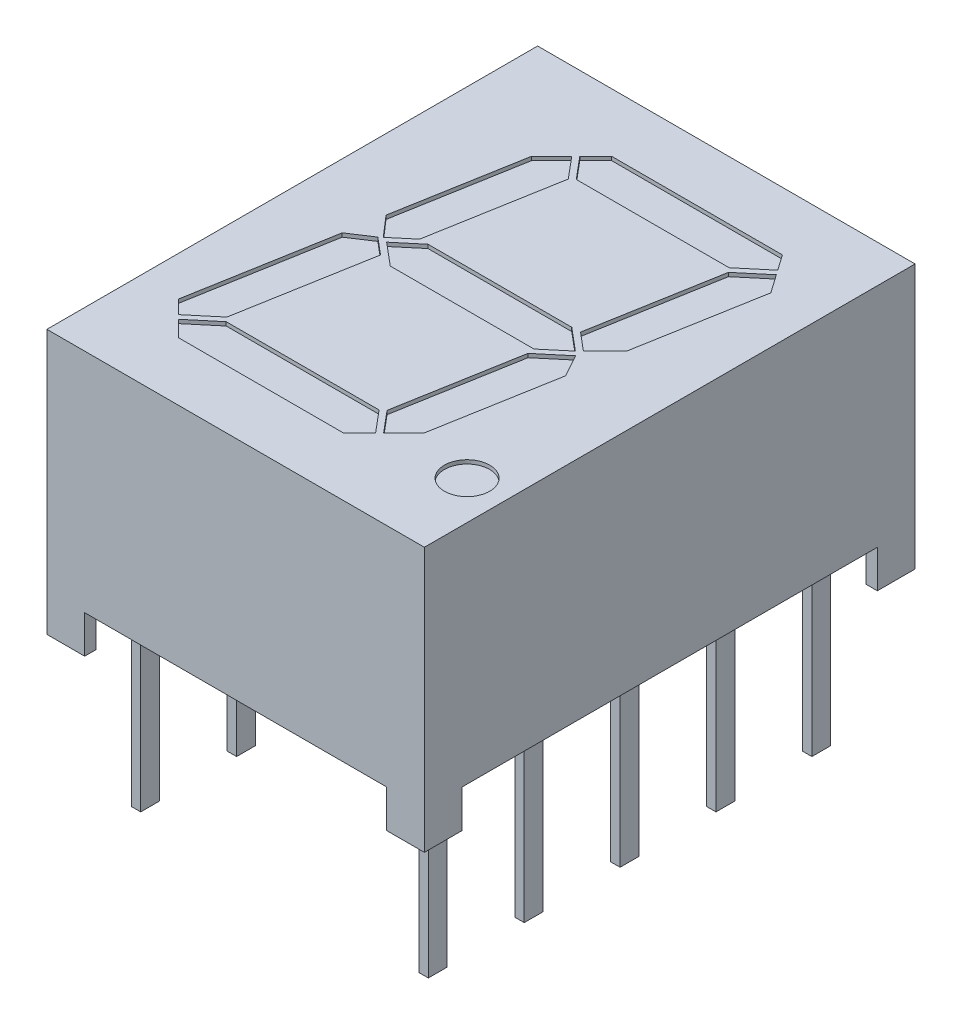
from build123d import *

# Parameters (mm, degrees)
SKETCH1_W          = 10
SKETCH1_H          = 13
EXTRUDE2_DEPTH     = 7
SKETCH2_W          = 4
SKETCH2_H          = 1
CUT_EXTRUDE2_DEPTH = 16.588457268
SKETCH3_W          = 11
SKETCH3_H          = 1
CUT_EXTRUDE3_DEPTH = 14.829316686
SKETCH6_R          = 0.6
CUT_EXTRUDE4_DEPTH = 0.1
SKETCH7_W          = 0.7
SKETCH7_H          = 0.7
CUT_EXTRUDE6_DEPTH = 1
SKETCH7_3_W        = 0.25
SKETCH7_3_H        = 0.5
EXTRUDE3_DEPTH     = 1
SKETCH7_4_W        = 0.7
SKETCH7_4_H        = 0.7
SKETCH7_4_W_2      = 0.25
SKETCH7_4_H_2      = 0.5
EXTRUDE4_DEPTH     = 4
SKETCH8_W          = 0.025316456
SKETCH8_H          = 0.026582279
SKETCH8_W_2        = 0.025316455
CUT_EXTRUDE7_DEPTH = 0.01


with BuildPart() as part:
    # Sketch1 → Extrude2 (new body)
    with BuildSketch(Plane(origin=(0, 0, 0), x_dir=(1, 0, 0), z_dir=(0, 1, 0))):
        Rectangle(SKETCH1_W, SKETCH1_H)
    extrude(amount=-EXTRUDE2_DEPTH)

    # Sketch2 → Cut-Extrude2 (cut, through all)
    with BuildSketch(Plane.XY.offset(6.5)):
        with Locations((-2, -6.5)):
            Rectangle(SKETCH2_W, SKETCH2_H)
        with Locations((2, -6.5)):
            Rectangle(SKETCH2_W, SKETCH2_H)
    extrude(amount=-CUT_EXTRUDE2_DEPTH, mode=Mode.SUBTRACT)

    # Sketch3 → Cut-Extrude3 (cut, through all)
    with BuildSketch(Plane(origin=(5, 0, 0), x_dir=(0, 0, -1), z_dir=(1, 0, 0))):
        with Locations((0, -6.5)):
            Rectangle(SKETCH3_W, SKETCH3_H)
    extrude(amount=-CUT_EXTRUDE3_DEPTH, mode=Mode.SUBTRACT)

    # Sketch6 → Cut-Extrude4 (cut)
    with BuildSketch(Plane(origin=(0, 0, 0), x_dir=(-1, 0, 0), z_dir=(0, 1, 0))):
        Polygon((2.01780111, -4.421729157), (2.550190438, -3.889339828), (3.128122122, -0.611726379), (2.654628224, -0.066062608), (2.131512729, -0.505008627), (1.541068921, -3.853581859), align=None)
        Polygon((2.733358574, 0), (3.302068733, 0.374773874), (3.952952037, 4.066116524), (3.596689581, 4.422378979), (2.896789804, 3.835093334), (2.286652218, 0.374831138), align=None)
        Polygon((1.489530267, -4.95), (1.911329938, -4.528200329), (1.426162255, -3.95), (-2.624044681, -3.95), (-3.323944459, -4.537285646), (-3.034958757, -4.95), align=None)
        Polygon((1.904123204, -0.5), (2.5, 0), (1.904123204, 0.5), (-1.904123204, 0.5), (-2.5, 0), (-1.904123204, -0.5), align=None)
        Polygon((2.800371662, 3.95), (3.490218409, 4.528850151), (3.069068561, 4.95), (-1.313203286, 4.95), (-1.735002957, 4.528200329), (-1.249835274, 3.95), align=None)
        Polygon((-3.41030957, -4.413943485), (-2.720462823, -3.835093334), (-2.133051387, -0.503717539), (-2.598749395, -0.112950513), (-3.18025084, -0.683910271), (-3.751929303, -3.926059945), align=None)
        Polygon((-1.924566889, 0.678656804), (-1.364741941, 3.853581859), (-1.841474129, 4.421729157), (-2.373863458, 3.889339828), (-2.936942063, 0.695962372), (-2.611721221, 0.102065858), align=None)
        with Locations(Location((-3.980686632, 4.35, 0), (0, 0, 90))):
            Circle(SKETCH6_R)
    extrude(amount=-CUT_EXTRUDE4_DEPTH, mode=Mode.SUBTRACT)

    # Sketch7 → Cut-Extrude6 (cut)
    with BuildSketch(Plane.XZ.offset(7)):
        with Locations((-4.35, 5.85)):
            Rectangle(SKETCH7_W, SKETCH7_H)
        with Locations((-4.35, -5.85)):
            Rectangle(SKETCH7_W, SKETCH7_H)
        with Locations((4.35, -5.85)):
            Rectangle(SKETCH7_W, SKETCH7_H)
        with Locations((4.35, 5.85)):
            Rectangle(SKETCH7_W, SKETCH7_H)
    extrude(amount=-CUT_EXTRUDE6_DEPTH, mode=Mode.SUBTRACT)

    # Sketch7_3 → Extrude3 (add)
    with BuildSketch(Plane.XZ.offset(7)):
        with Locations((-3.81, 5.08)):
            Rectangle(SKETCH7_3_W, SKETCH7_3_H)
        with Locations((3.81, -5.08)):
            Rectangle(SKETCH7_3_W, SKETCH7_3_H)
        with Locations((-3.81, 2.54)):
            Rectangle(SKETCH7_3_W, SKETCH7_3_H)
        with Locations((-3.81, 0)):
            Rectangle(SKETCH7_3_W, SKETCH7_3_H)
        with Locations((-3.81, -2.54)):
            Rectangle(SKETCH7_3_W, SKETCH7_3_H)
        with Locations((-3.81, -5.08)):
            Rectangle(SKETCH7_3_W, SKETCH7_3_H)
        with Locations((3.81, -2.54)):
            Rectangle(SKETCH7_3_W, SKETCH7_3_H)
        with Locations((3.81, 0)):
            Rectangle(SKETCH7_3_W, SKETCH7_3_H)
        with Locations((3.81, 2.54)):
            Rectangle(SKETCH7_3_W, SKETCH7_3_H)
        with Locations((3.81, 5.08)):
            Rectangle(SKETCH7_3_W, SKETCH7_3_H)
    extrude(amount=-EXTRUDE3_DEPTH)


with BuildPart() as extrude4_tool:
    # Sketch7_4 → Extrude4 (new body)
    with BuildSketch(Plane.XZ.offset(7)):
        with Locations((-4.35, 5.85)):
            Rectangle(SKETCH7_4_W, SKETCH7_4_H)
        with Locations((-4.35, -5.85)):
            Rectangle(SKETCH7_4_W, SKETCH7_4_H)
        with Locations((4.35, -5.85)):
            Rectangle(SKETCH7_4_W, SKETCH7_4_H)
        with Locations((4.35, 5.85)):
            Rectangle(SKETCH7_4_W, SKETCH7_4_H)
        with Locations((-3.81, 5.08)):
            Rectangle(SKETCH7_4_W_2, SKETCH7_4_H_2)
        with Locations((3.81, -5.08)):
            Rectangle(SKETCH7_4_W_2, SKETCH7_4_H_2)
        with Locations((-3.81, 2.54)):
            Rectangle(SKETCH7_4_W_2, SKETCH7_4_H_2)
        with Locations((-3.81, 0)):
            Rectangle(SKETCH7_4_W_2, SKETCH7_4_H_2)
        with Locations((-3.81, -2.54)):
            Rectangle(SKETCH7_4_W_2, SKETCH7_4_H_2)
        with Locations((-3.81, -5.08)):
            Rectangle(SKETCH7_4_W_2, SKETCH7_4_H_2)
        with Locations((3.81, -2.54)):
            Rectangle(SKETCH7_4_W_2, SKETCH7_4_H_2)
        with Locations((3.81, 0)):
            Rectangle(SKETCH7_4_W_2, SKETCH7_4_H_2)
        with Locations((3.81, 2.54)):
            Rectangle(SKETCH7_4_W_2, SKETCH7_4_H_2)
        with Locations((3.81, 5.08)):
            Rectangle(SKETCH7_4_W_2, SKETCH7_4_H_2)
    extrude(amount=EXTRUDE4_DEPTH)


with BuildPart() as part_1:
    add(part.part)


with BuildPart() as part_2:
    # Extrude4: joined with extrude4_tool
    add(part_1.part.fuse(extrude4_tool.part, tol=0.00001))


with BuildPart() as extrude4_kept_piece:
    # of the separate pieces the step leaves, the one the design keeps (extrude4_pieces_kept)
    add(part_2.part.solids().sort_by_distance((-5, 0, -6.5))[0])

    # Sketch8 → Cut-Extrude7 (cut)
    with BuildSketch(Plane.XZ.offset(6)):
        Polygon((0.542632818, 5.007606152), (0.566090097, 5.082289696), (0.590832977, 5.082289696), (0.607249116, 5.031953462), (0.622775223, 5.082289696), (0.648507027, 5.082289696), (0.671746742, 5.007606152), (0.646568736, 5.007606152), (0.633574274, 5.059089538), (0.617158135, 5.007606152), (0.595658926, 5.007606152), (0.579341679, 5.059089538), (0.566525223, 5.007606152), align=None)
        Polygon((0.408455622, 5.007535676), (0.4319129, 5.08221922), (0.45665578, 5.08221922), (0.473071919, 5.031882986), (0.488598027, 5.08221922), (0.514329831, 5.08221922), (0.537569546, 5.007535676), (0.512391539, 5.007535676), (0.499397077, 5.059019062), (0.482980938, 5.007535676), (0.461481729, 5.007535676), (0.445164483, 5.059019062), (0.432348027, 5.007535676), align=None)
        Polygon((0.274278425, 5.0074652), (0.297735704, 5.082148744), (0.322478583, 5.082148744), (0.338894723, 5.03181251), (0.35442083, 5.082148744), (0.380152634, 5.082148744), (0.403392349, 5.0074652), (0.378214343, 5.0074652), (0.365219881, 5.058948586), (0.348803742, 5.0074652), (0.327304533, 5.0074652), (0.310987286, 5.058948586), (0.29817083, 5.0074652), align=None)
        with Locations((0.246430342, 5.068787129)):
            Rectangle(SKETCH8_W, SKETCH8_H)
        with BuildLine():
            add(Edge.make_bspline(
                [(0.129974653, 5.050881452), (0.130011181, 5.052103566), (0.13008291, 5.05450339), (0.130692072, 5.058011356), (0.131687596, 5.061334639), (0.133051935, 5.064497355), (0.134865923, 5.067452721), (0.137020936, 5.070271288), (0.139632851, 5.07285525), (0.142569887, 5.075294011), (0.145867814, 5.077476406), (0.149470436, 5.079376544), (0.153340756, 5.081001263), (0.157494777, 5.082332953), (0.161940354, 5.08332372), (0.166658131, 5.084047037), (0.171651479, 5.084520545), (0.175075067, 5.084562486), (0.176829874, 5.084583984)],
                knots=[0, 0, 0, 0, 0.907421153, 1.781872267, 2.635683434, 3.480115191, 4.332689235, 5.205575272, 6.109500117, 7.055808355, 8.037942167, 9.041423561, 10.07750834, 11.152467461, 12.277657752, 13.45734338, 14.696726425, 16, 16, 16, 16], degree=3))
            add(Edge.make_bspline(
                [(0.176829874, 5.084583984), (0.178847859, 5.084556719), (0.182756045, 5.084503915), (0.188423613, 5.084118542), (0.19368708, 5.083430592), (0.198584827, 5.082474012), (0.203189127, 5.081270727), (0.207622472, 5.079980083), (0.211903764, 5.078515502), (0.214676856, 5.077415366), (0.216050602, 5.076870376)],
                knots=[0, 0, 0, 0, 1.203182053, 2.33017619, 3.384818652, 4.366208123, 5.30340534, 6.221361684, 7.118890722, 8, 8, 8, 8], degree=3))
            Line((0.216050602, 5.076870376), (0.216050602, 5.052938414))
            Line((0.216050602, 5.052938414), (0.213202501, 5.052938414))
            add(Edge.make_bspline(
                [(0.213202501, 5.052938414), (0.211836938, 5.054019377), (0.209113828, 5.056174956), (0.20468687, 5.05894331), (0.200027858, 5.06131632), (0.195189464, 5.063298943), (0.190288096, 5.064874557), (0.185419028, 5.066001463), (0.180650046, 5.066740827), (0.177491724, 5.066822388), (0.175939843, 5.066862465)],
                knots=[0, 0, 0, 0, 1.030738938, 2.055426519, 3.085610749, 4.123842265, 5.148648843, 6.130724483, 7.081507926, 8, 8, 8, 8], degree=3))
            add(Edge.make_bspline(
                [(0.175939843, 5.066862465), (0.175511097, 5.066861164), (0.174593184, 5.066858379), (0.173124036, 5.066737064), (0.171467693, 5.06660922), (0.169686954, 5.066413106), (0.16789975, 5.066181961), (0.166239502, 5.065835494), (0.16473874, 5.065466343), (0.163832071, 5.065099077), (0.163400286, 5.064924173)],
                knots=[0, 0, 0, 0, 0.806537132, 1.726733348, 2.77251655, 3.932999672, 5.098049949, 6.161349231, 7.124375527, 8, 8, 8, 8], degree=3))
            add(Edge.make_bspline(
                [(0.163400286, 5.064924173), (0.1629208, 5.064695938), (0.161978507, 5.064247406), (0.160675976, 5.063433496), (0.159505491, 5.062538751), (0.158444789, 5.061577018), (0.157582394, 5.06041403), (0.156961233, 5.059014759), (0.156616662, 5.057365466), (0.15657759, 5.056190304), (0.156556931, 5.055568952)],
                knots=[0, 0, 0, 0, 1.02474257, 2.013837243, 2.958431669, 3.867978675, 4.769292696, 5.732237074, 6.800947934, 8, 8, 8, 8], degree=3))
            add(Edge.make_bspline(
                [(0.156556931, 5.055568952), (0.156588393, 5.055023086), (0.156650255, 5.053949752), (0.157231761, 5.052421322), (0.158115808, 5.051001186), (0.159395223, 5.04973585), (0.161008902, 5.048609738), (0.162939889, 5.047598975), (0.165213739, 5.046763217), (0.166850952, 5.046325345), (0.167711995, 5.04609506)],
                knots=[0, 0, 0, 0, 0.825427492, 1.623033598, 2.45033906, 3.348940377, 4.33183287, 5.428402891, 6.647546779, 8, 8, 8, 8], degree=3))
            add(Edge.make_bspline(
                [(0.167711995, 5.04609506), (0.169681235, 5.045649855), (0.173716447, 5.044737577), (0.17985626, 5.043550123), (0.185994963, 5.042324252), (0.18995122, 5.041109937), (0.191881298, 5.040517528)],
                knots=[0, 0, 0, 0, 0.976118991, 2.000185432, 3.024380873, 4, 4, 4, 4], degree=3))
            add(Edge.make_bspline(
                [(0.191881298, 5.040517528), (0.192919451, 5.040163805), (0.194940313, 5.039475251), (0.197839505, 5.038322602), (0.200482753, 5.037017468), (0.202940292, 5.03569543), (0.205132956, 5.034215372), (0.20712759, 5.032682613), (0.20888025, 5.031029808), (0.210406688, 5.029280316), (0.211749554, 5.027443954), (0.212902964, 5.025496813), (0.213863986, 5.023430363), (0.214687378, 5.021274966), (0.215298605, 5.019000431), (0.215721041, 5.016624014), (0.216019104, 5.014140527), (0.21603996, 5.012446192), (0.216050602, 5.01158161)],
                knots=[0, 0, 0, 0, 1.287376879, 2.505999703, 3.65855109, 4.746193839, 5.778582289, 6.760029101, 7.696159662, 8.601061861, 9.48181646, 10.363080883, 11.252765705, 12.153987336, 13.068239035, 14.012364187, 14.985753787, 16, 16, 16, 16], degree=3))
            add(Edge.make_bspline(
                [(0.216050602, 5.01158161), (0.216013302, 5.010425464), (0.215939895, 5.008150189), (0.215338445, 5.004821166), (0.214311935, 5.001672348), (0.212925575, 4.998669192), (0.211098082, 4.995854928), (0.208905959, 4.993177442), (0.206295649, 4.990684946), (0.203310322, 4.988386309), (0.200023475, 4.986307504), (0.19648947, 4.984470796), (0.192710618, 4.982964349), (0.188730733, 4.981683118), (0.184511341, 4.980730722), (0.18007437, 4.980011145), (0.175400508, 4.979598144), (0.172209097, 4.979546869), (0.170579874, 4.979520692)],
                knots=[0, 0, 0, 0, 0.894901293, 1.761149761, 2.608783409, 3.453876344, 4.314933854, 5.200038827, 6.12799933, 7.103249695, 8.113098521, 9.136064399, 10.182719798, 11.259667356, 12.370545059, 13.528828137, 14.738461593, 16, 16, 16, 16], degree=3))
            add(Edge.make_bspline(
                [(0.170579874, 4.979520692), (0.168911223, 4.979543085), (0.165576749, 4.979587833), (0.160594776, 4.979962802), (0.155637361, 4.980529304), (0.150765797, 4.981328758), (0.14608329, 4.982346414), (0.141666676, 4.983432372), (0.137587706, 4.984672762), (0.135013981, 4.985626807), (0.133772121, 4.986087148)],
                knots=[0, 0, 0, 0, 1.065379838, 2.128953261, 3.188461447, 4.250817766, 5.279613205, 6.247547721, 7.154416075, 8, 8, 8, 8], degree=3))
            Line((0.133772121, 4.986087148), (0.133772121, 5.008634616))
            Line((0.133772121, 5.008634616), (0.136600444, 5.008634616))
            add(Edge.make_bspline(
                [(0.136600444, 5.008634616), (0.137673404, 5.007834413), (0.139867634, 5.006197975), (0.143526387, 5.004111998), (0.147490447, 5.002162484), (0.151755349, 5.000440691), (0.156227889, 4.99902009), (0.160805435, 4.997991046), (0.1654325, 4.997351923), (0.168534091, 4.99727879), (0.170085412, 4.997242211)],
                knots=[0, 0, 0, 0, 0.89224925, 1.824673196, 2.804309561, 3.838364047, 4.890042674, 5.931526337, 6.965412421, 8, 8, 8, 8], degree=3))
            add(Edge.make_bspline(
                [(0.170085412, 4.997242211), (0.171180712, 4.997266421), (0.173370458, 4.997314822), (0.176644865, 4.997664076), (0.179879657, 4.998335817), (0.181922555, 4.999150154), (0.182941425, 4.999556294)],
                knots=[0, 0, 0, 0, 0.998993879, 1.997209027, 3.00113285, 4, 4, 4, 4], degree=3))
            add(Edge.make_bspline(
                [(0.182941425, 4.999556294), (0.183374904, 4.999757776), (0.184241574, 5.000160608), (0.185448577, 5.000932933), (0.186551881, 5.001862651), (0.187552886, 5.002915045), (0.188400942, 5.00408438), (0.189038602, 5.005354139), (0.189399422, 5.006716118), (0.189445258, 5.007650286), (0.189468324, 5.008120376)],
                knots=[0, 0, 0, 0, 1.005454979, 2.010239304, 3.005296729, 4.036100111, 5.060531193, 6.034954812, 7.011155677, 8, 8, 8, 8], degree=3))
            add(Edge.make_bspline(
                [(0.189468324, 5.008120376), (0.189433529, 5.008758307), (0.189367041, 5.009977335), (0.188767043, 5.011691031), (0.187769374, 5.013154143), (0.186616275, 5.014147136), (0.185499296, 5.014845896), (0.184458779, 5.015351136), (0.183259328, 5.015864559), (0.181881879, 5.016353756), (0.180346744, 5.016847802), (0.178637822, 5.017322472), (0.176755214, 5.017772031), (0.175439324, 5.018058183), (0.174753134, 5.018207401)],
                knots=[0, 0, 0, 0, 1.174343879, 2.244064321, 3.303704314, 4.407076671, 5.02483983, 5.732197225, 6.53898402, 7.431906431, 8.428480183, 9.514816237, 10.704066255, 12, 12, 12, 12], degree=3))
            add(Edge.make_bspline(
                [(0.174753134, 5.018207401), (0.172920509, 5.018584121), (0.169319806, 5.019324293), (0.163914731, 5.02041859), (0.158421677, 5.021731107), (0.154751127, 5.02286032), (0.152838577, 5.023448699)],
                knots=[0, 0, 0, 0, 0.995788186, 1.956503735, 2.935230479, 4, 4, 4, 4], degree=3))
            add(Edge.make_bspline(
                [(0.152838577, 5.023448699), (0.15189202, 5.02376794), (0.150040403, 5.024392428), (0.147399805, 5.025478746), (0.144952632, 5.026652603), (0.142685998, 5.027894573), (0.140610632, 5.029237006), (0.138724342, 5.030662339), (0.137026385, 5.032167122), (0.135537637, 5.033782842), (0.134208879, 5.03549319), (0.133096535, 5.037343803), (0.13210095, 5.039287332), (0.131347795, 5.041380775), (0.130723286, 5.043579303), (0.130301543, 5.045911237), (0.13000718, 5.048355455), (0.129985616, 5.050030054), (0.129974653, 5.050881452)],
                knots=[0, 0, 0, 0, 1.237326419, 2.420410185, 3.534642089, 4.598489486, 5.620241961, 6.59385002, 7.525152549, 8.426792174, 9.312230456, 10.203151844, 11.098070343, 12.012931196, 12.954244379, 13.926618287, 14.945853925, 16, 16, 16, 16], degree=3))
        make_face()
        with BuildLine():
            Line((0.037569603, 5.082001143), (0.061620236, 5.082001143))
            Line((0.061620236, 5.082001143), (0.061620236, 5.074168865))
            add(Edge.make_bspline(
                [(0.061620236, 5.074168865), (0.06271343, 5.074977659), (0.064821091, 5.076537004), (0.067995651, 5.078614066), (0.07101395, 5.080398488), (0.073944303, 5.081921605), (0.076950579, 5.083133776), (0.080188714, 5.083952157), (0.08369031, 5.084454881), (0.08611738, 5.084506242), (0.087371818, 5.084532789)],
                knots=[0, 0, 0, 0, 1.150945962, 2.219006967, 3.209666795, 4.118194914, 5.012574058, 5.946577101, 6.93868214, 8, 8, 8, 8], degree=3))
            add(Edge.make_bspline(
                [(0.087371818, 5.084532789), (0.088388093, 5.084509841), (0.090367074, 5.084465155), (0.093245374, 5.084123434), (0.09594734, 5.083575025), (0.098476177, 5.082806619), (0.100825877, 5.081803588), (0.102969557, 5.080531953), (0.104972133, 5.079099239), (0.106754081, 5.077392874), (0.108369627, 5.075494955), (0.109752198, 5.073362546), (0.110929903, 5.071029606), (0.111871002, 5.068477756), (0.112626091, 5.065719452), (0.113150023, 5.062740205), (0.113470616, 5.059553077), (0.113502555, 5.057357947), (0.11351897, 5.056229782)],
                knots=[0, 0, 0, 0, 1.108959949, 2.159465255, 3.158589008, 4.114545495, 5.039534357, 5.93921201, 6.830099133, 7.720870013, 8.624681761, 9.544731627, 10.487599671, 11.471264588, 12.508152322, 13.604835107, 14.769030043, 16, 16, 16, 16], degree=3))
            Line((0.11351897, 5.056229782), (0.11351897, 5.007317599))
            Line((0.11351897, 5.007317599), (0.089468337, 5.007317599))
            Line((0.089468337, 5.007317599), (0.089468337, 5.044896713))
            add(Edge.make_bspline(
                [(0.089468337, 5.044896713), (0.089466702, 5.045813184), (0.089463571, 5.047567399), (0.089381232, 5.050073206), (0.089260332, 5.052341378), (0.089121627, 5.054383407), (0.08886861, 5.056230158), (0.088490902, 5.057896319), (0.088020076, 5.059415921), (0.087555757, 5.060322622), (0.087332261, 5.060759054)],
                knots=[0, 0, 0, 0, 1.361401701, 2.605856924, 3.723918663, 4.735739235, 5.645738665, 6.489217889, 7.27279937, 8, 8, 8, 8], degree=3))
            add(Edge.make_bspline(
                [(0.087332261, 5.060759054), (0.087102253, 5.06115776), (0.086650076, 5.061941581), (0.085729812, 5.062947893), (0.084650969, 5.063791643), (0.083373766, 5.064449744), (0.081884199, 5.064940247), (0.08016334, 5.065320818), (0.078171598, 5.065492696), (0.07676413, 5.065527186), (0.07601897, 5.065545447)],
                knots=[0, 0, 0, 0, 0.849004071, 1.669068917, 2.503060811, 3.370079215, 4.310762265, 5.396376419, 6.621555549, 8, 8, 8, 8], degree=3))
            add(Edge.make_bspline(
                [(0.07601897, 5.065545447), (0.075478028, 5.065525608), (0.074366611, 5.065484846), (0.072649158, 5.065293305), (0.070859899, 5.064894147), (0.06834123, 5.064249202), (0.06517602, 5.063055348), (0.062816486, 5.061702201), (0.061620236, 5.061016175)],
                knots=[0, 0, 0, 0, 0.638062719, 1.310959128, 2.033463623, 2.796942592, 4.376095945, 6, 6, 6, 6], degree=3))
            Line((0.061620236, 5.061016175), (0.061620236, 5.007317599))
            Line((0.061620236, 5.007317599), (0.037569603, 5.007317599))
            Line((0.037569603, 5.007317599), (0.037569603, 5.082001143))
        make_face()
        with BuildLine():
            Line((-0.059898738, 5.081949948), (-0.035848105, 5.081949948))
            Line((-0.035848105, 5.081949948), (-0.035848105, 5.044370834))
            add(Edge.make_bspline(
                [(-0.035848105, 5.044370834), (-0.035823099, 5.042840845), (-0.035773127, 5.039783353), (-0.035496576, 5.036020259), (-0.035112089, 5.03317872), (-0.03474455, 5.031347131), (-0.034312678, 5.029799014), (-0.033900417, 5.028913253), (-0.033712029, 5.028508492)],
                knots=[0, 0, 0, 0, 1.709111167, 3.415443484, 4.21113913, 4.910175115, 5.501990373, 6, 6, 6, 6], degree=3))
            add(Edge.make_bspline(
                [(-0.033712029, 5.028508492), (-0.033467568, 5.02811043), (-0.032988268, 5.027329971), (-0.032050918, 5.026317095), (-0.030957134, 5.025487726), (-0.029685958, 5.024808259), (-0.028197849, 5.024329071), (-0.026473932, 5.023976317), (-0.024493747, 5.023765763), (-0.023084918, 5.02373721), (-0.022339402, 5.0237221)],
                knots=[0, 0, 0, 0, 0.860202684, 1.686548532, 2.528236983, 3.382486038, 4.33249885, 5.401154041, 6.624757403, 8, 8, 8, 8], degree=3))
            add(Edge.make_bspline(
                [(-0.022339402, 5.0237221), (-0.021208513, 5.023782201), (-0.018900818, 5.023904842), (-0.016025508, 5.024571508), (-0.01370817, 5.025431473), (-0.011850453, 5.026181908), (-0.009942731, 5.027156009), (-0.008663189, 5.02787745), (-0.008000004, 5.028251372)],
                knots=[0, 0, 0, 0, 1.33818541, 2.730705359, 3.468371228, 4.262126284, 5.099261778, 6, 6, 6, 6], degree=3))
            Line((-0.008000004, 5.028251372), (-0.008000004, 5.081949948))
            Line((-0.008000004, 5.081949948), (0.016050629, 5.081949948))
            Line((0.016050629, 5.081949948), (0.016050629, 5.007266404))
            Line((0.016050629, 5.007266404), (-0.008000004, 5.007266404))
            Line((-0.008000004, 5.007266404), (-0.008000004, 5.015098682))
            add(Edge.make_bspline(
                [(-0.008000004, 5.015098682), (-0.00905741, 5.014292531), (-0.011115715, 5.012723309), (-0.014294953, 5.010682888), (-0.017378851, 5.008884119), (-0.020431861, 5.007371302), (-0.023546815, 5.006164527), (-0.026809574, 5.005353538), (-0.03022598, 5.004809736), (-0.032562695, 5.004760042), (-0.033751586, 5.004734758)],
                knots=[0, 0, 0, 0, 1.126119141, 2.192057864, 3.198061997, 4.149848529, 5.076251285, 6.021887753, 6.99356175, 8, 8, 8, 8], degree=3))
            add(Edge.make_bspline(
                [(-0.033751586, 5.004734758), (-0.034747851, 5.004760159), (-0.036692738, 5.004809745), (-0.039527587, 5.005119297), (-0.042198693, 5.00567052), (-0.044692078, 5.006466376), (-0.047027764, 5.007457735), (-0.049201436, 5.008661715), (-0.051187285, 5.010124996), (-0.053015437, 5.011784935), (-0.054654537, 5.013676232), (-0.056051447, 5.01580561), (-0.057255809, 5.01814253), (-0.058205074, 5.020705168), (-0.058996398, 5.023471439), (-0.059501162, 5.026470069), (-0.059858814, 5.029679955), (-0.059885164, 5.031896105), (-0.059898738, 5.033037765)],
                knots=[0, 0, 0, 0, 1.08828964, 2.12453497, 3.110382522, 4.062402335, 4.978696626, 5.878225494, 6.769849763, 7.667011675, 8.57076823, 9.495541561, 10.442454184, 11.436213583, 12.475881554, 13.580560132, 14.753614518, 16, 16, 16, 16], degree=3))
            Line((-0.059898738, 5.033037765), (-0.059898738, 5.081949948))
        make_face()
        Polygon((-0.154835433, 5.081898753), (-0.082683535, 5.081898753), (-0.082683535, 4.981898753), (-0.10799999, 4.981898753), (-0.10799999, 5.062911411), (-0.154835433, 5.062911411), align=None)
        Polygon((-0.242177193, 5.081852877), (-0.170025295, 5.081852877), (-0.170025295, 4.981852877), (-0.242177193, 4.981852877), (-0.242177193, 5.000840219), (-0.19534175, 5.000840219), (-0.19534175, 5.018561738), (-0.238379725, 5.018561738), (-0.238379725, 5.03754908), (-0.19534175, 5.03754908), (-0.19534175, 5.062865536), (-0.242177193, 5.062865536), align=None)
        with BuildLine():
            add(Edge.make_bspline(
                [(-0.358632877, 5.031902569), (-0.358613561, 5.033050258), (-0.358575309, 5.035323144), (-0.358280118, 5.038687951), (-0.357754093, 5.041953626), (-0.357074911, 5.045137875), (-0.356152405, 5.048216803), (-0.355070692, 5.05122438), (-0.353761046, 5.054129873), (-0.352256193, 5.056931308), (-0.350606721, 5.059603411), (-0.348831972, 5.062123619), (-0.346986193, 5.064506837), (-0.34499688, 5.066701731), (-0.342917698, 5.068743751), (-0.34074217, 5.070634565), (-0.338437106, 5.072337996), (-0.336829943, 5.07336088), (-0.336026073, 5.073872506)],
                knots=[0, 0, 0, 0, 1.105570398, 2.18947457, 3.250358341, 4.290584537, 5.323553275, 6.344225964, 7.367641686, 8.3905646, 9.405808457, 10.390761353, 11.358902336, 12.307789878, 13.241960776, 14.165076779, 15.082208636, 16, 16, 16, 16], degree=3))
            add(Edge.make_bspline(
                [(-0.336026073, 5.073872506), (-0.334786886, 5.074584827), (-0.332302189, 5.076013104), (-0.32831773, 5.077678943), (-0.324196122, 5.079093166), (-0.319836941, 5.080106607), (-0.31519822, 5.080876442), (-0.310193409, 5.081424613), (-0.304786502, 5.081730116), (-0.30105151, 5.081778598), (-0.299119427, 5.081803677)],
                knots=[0, 0, 0, 0, 0.896321744, 1.797216976, 2.705381885, 3.628777036, 4.602292017, 5.655629376, 6.787275635, 8, 8, 8, 8], degree=3))
            Line((-0.299119427, 5.081803677), (-0.263696168, 5.081803677))
            Line((-0.263696168, 5.081803677), (-0.263696168, 4.981803677))
            Line((-0.263696168, 4.981803677), (-0.30012813, 4.981803677))
            add(Edge.make_bspline(
                [(-0.30012813, 4.981803677), (-0.302106826, 4.981820487), (-0.305923485, 4.981852912), (-0.311440802, 4.982267839), (-0.31654314, 4.982873602), (-0.32123272, 4.983767788), (-0.32553517, 4.984882369), (-0.329452461, 4.9862709), (-0.333068695, 4.987763517), (-0.33524723, 4.989038071), (-0.336302972, 4.989655734)],
                knots=[0, 0, 0, 0, 1.267083275, 2.444046388, 3.541868212, 4.55639609, 5.499737919, 6.385160515, 7.217431253, 8, 8, 8, 8], degree=3))
            add(Edge.make_bspline(
                [(-0.336302972, 4.989655734), (-0.337153925, 4.990192275), (-0.33884605, 4.991259188), (-0.341247264, 4.99304104), (-0.343476692, 4.994997117), (-0.345605194, 4.997048936), (-0.347585012, 4.999251823), (-0.349428212, 5.00159053), (-0.351132029, 5.004068624), (-0.352689992, 5.006678093), (-0.354110807, 5.009408145), (-0.355300113, 5.012281204), (-0.356349462, 5.015259734), (-0.357154998, 5.018368696), (-0.357852912, 5.021576533), (-0.358287647, 5.024917877), (-0.358574258, 5.028370365), (-0.358613173, 5.030715255), (-0.358632877, 5.031902569)],
                knots=[0, 0, 0, 0, 0.964065863, 1.917049184, 2.86229036, 3.805247319, 4.749389377, 5.698846072, 6.657678277, 7.629829384, 8.610569287, 9.604676042, 10.607940105, 11.6349849, 12.681042988, 13.752616828, 14.862056989, 16, 16, 16, 16], degree=3))
        make_face()
        with BuildLine():
            add(Edge.make_bspline(
                [(-0.332050598, 5.031744342), (-0.332007296, 5.030165911), (-0.331923683, 5.027118112), (-0.331218288, 5.022722468), (-0.330079039, 5.018679518), (-0.328741346, 5.015567102), (-0.327403955, 5.013293784), (-0.326276431, 5.011695514), (-0.325026765, 5.010181314), (-0.323636156, 5.008772474), (-0.322100972, 5.007465438), (-0.320439713, 5.006236527), (-0.318639672, 5.005107882), (-0.31736664, 5.004447876), (-0.316722275, 5.004113804)],
                knots=[0, 0, 0, 0, 1.694683197, 3.272273219, 4.767406206, 6.197615014, 6.895990032, 7.597410435, 8.296503208, 9.002591366, 9.720792421, 10.460154445, 11.220583224, 12, 12, 12, 12], degree=3))
            add(Edge.make_bspline(
                [(-0.316722275, 5.004113804), (-0.31604734, 5.003807289), (-0.314709572, 5.003199756), (-0.312639297, 5.00246567), (-0.310546595, 5.001903343), (-0.308352368, 5.00143092), (-0.305875608, 5.001153784), (-0.302953117, 5.000941107), (-0.299496444, 5.00080418), (-0.297009848, 5.000795609), (-0.295677972, 5.000791019)],
                knots=[0, 0, 0, 0, 0.826913061, 1.638999358, 2.447478739, 3.243919028, 4.140906711, 5.225381046, 6.513851968, 8, 8, 8, 8], degree=3))
            Line((-0.295677972, 5.000791019), (-0.289012624, 5.000791019))
            Line((-0.289012624, 5.000791019), (-0.289012624, 5.062816335))
            Line((-0.289012624, 5.062816335), (-0.295677972, 5.062816335))
            add(Edge.make_bspline(
                [(-0.295677972, 5.062816335), (-0.296436163, 5.06281129), (-0.297899898, 5.062801549), (-0.300016352, 5.062762446), (-0.301981113, 5.062702129), (-0.303788464, 5.062630287), (-0.305444601, 5.062515384), (-0.306932434, 5.062346787), (-0.308274785, 5.062202399), (-0.309842419, 5.06193528), (-0.311695568, 5.061518825), (-0.313856834, 5.060840733), (-0.315997367, 5.059990314), (-0.31738594, 5.05930535), (-0.318086991, 5.058959531)],
                knots=[0, 0, 0, 0, 1.186775798, 2.291144404, 3.313233901, 4.263515562, 5.122260739, 5.910868134, 6.60717912, 7.234883681, 8.398964994, 9.577230746, 10.776813768, 12, 12, 12, 12], degree=3))
            add(Edge.make_bspline(
                [(-0.318086991, 5.058959531), (-0.318670705, 5.058616055), (-0.319818642, 5.057940571), (-0.321462786, 5.056834708), (-0.322949526, 5.055599709), (-0.324355587, 5.054316611), (-0.325608454, 5.052926157), (-0.326781747, 5.051475677), (-0.327792003, 5.049913284), (-0.329036997, 5.047719755), (-0.33025673, 5.044686385), (-0.331297489, 5.040719841), (-0.331934005, 5.036359832), (-0.332010738, 5.03332225), (-0.332050598, 5.031744342)],
                knots=[0, 0, 0, 0, 0.755109416, 1.485004392, 2.205961541, 2.908125208, 3.605307969, 4.290649036, 4.985852759, 5.676964147, 7.100721462, 8.614478074, 10.241350405, 12, 12, 12, 12], degree=3))
        make_face(mode=Mode.SUBTRACT)
        with Locations((-0.39027843, 5.068452699)):
            Rectangle(SKETCH8_W_2, SKETCH8_H)
        with BuildLine():
            add(Edge.make_bspline(
                [(-0.464922411, 5.084249554), (-0.463332306, 5.084227728), (-0.460211183, 5.084184886), (-0.455639739, 5.083708185), (-0.451274936, 5.082989718), (-0.447127318, 5.081971546), (-0.443220756, 5.080615204), (-0.439539703, 5.078997189), (-0.436150341, 5.076979383), (-0.434086611, 5.075402442), (-0.433059278, 5.074617434)],
                knots=[0, 0, 0, 0, 1.123606455, 2.205459211, 3.245124445, 4.248821949, 5.220056174, 6.165006393, 7.086533249, 8, 8, 8, 8], degree=3))
            add(Edge.make_bspline(
                [(-0.433059278, 5.074617434), (-0.432107531, 5.07376266), (-0.430207716, 5.072056417), (-0.427741783, 5.06908499), (-0.425618698, 5.065801946), (-0.423833145, 5.062199724), (-0.422402221, 5.058282995), (-0.421379088, 5.054038333), (-0.420759842, 5.049477552), (-0.420692677, 5.046329618), (-0.420658171, 5.044712371)],
                knots=[0, 0, 0, 0, 0.916457077, 1.82937027, 2.759194969, 3.714948755, 4.706655623, 5.743329475, 6.840637961, 8, 8, 8, 8], degree=3))
            add(Edge.make_bspline(
                [(-0.420658171, 5.044712371), (-0.420696931, 5.043009144), (-0.420772054, 5.039708064), (-0.421435814, 5.034935876), (-0.422505426, 5.030518196), (-0.424042984, 5.026466287), (-0.425973426, 5.022773096), (-0.428237919, 5.019401261), (-0.430858444, 5.016358337), (-0.432865583, 5.014612897), (-0.433870196, 5.01373927)],
                knots=[0, 0, 0, 0, 1.171797512, 2.271099083, 3.308930235, 4.294129479, 5.24602549, 6.17106565, 7.084581485, 8, 8, 8, 8], degree=3))
            add(Edge.make_bspline(
                [(-0.433870196, 5.01373927), (-0.43489611, 5.012970808), (-0.436960328, 5.011424604), (-0.440363172, 5.009521993), (-0.443990862, 5.007933799), (-0.447812598, 5.00665708), (-0.451787583, 5.005702463), (-0.455851138, 5.005009796), (-0.459994939, 5.004581114), (-0.46278532, 5.004528977), (-0.464190607, 5.004502719)],
                knots=[0, 0, 0, 0, 0.952046378, 1.915591786, 2.889970712, 3.892742799, 4.906722985, 5.925995921, 6.955492795, 8, 8, 8, 8], degree=3))
            add(Edge.make_bspline(
                [(-0.464190607, 5.004502719), (-0.465437412, 5.004519116), (-0.467889052, 5.00455136), (-0.471487892, 5.004881963), (-0.474945851, 5.0053839), (-0.478252769, 5.006122473), (-0.481419766, 5.00704409), (-0.484473905, 5.008076152), (-0.487433137, 5.009211383), (-0.489333782, 5.01009566), (-0.490278424, 5.010535156)],
                knots=[0, 0, 0, 0, 1.107549047, 2.177816721, 3.208424937, 4.210433793, 5.185680559, 6.13785309, 7.074491882, 8, 8, 8, 8], degree=3))
            Line((-0.490278424, 5.010535156), (-0.490278424, 5.031084997))
            Line((-0.490278424, 5.031084997), (-0.486935861, 5.031084997))
            add(Edge.make_bspline(
                [(-0.486935861, 5.031084997), (-0.486435283, 5.030669111), (-0.485350258, 5.029767659), (-0.483583426, 5.028321071), (-0.481413107, 5.026820781), (-0.479766077, 5.025926156), (-0.478886019, 5.02544813)],
                knots=[0, 0, 0, 0, 0.792743043, 1.718305972, 2.780820752, 4, 4, 4, 4], degree=3))
            add(Edge.make_bspline(
                [(-0.478886019, 5.02544813), (-0.477957083, 5.025009492), (-0.476051175, 5.024109532), (-0.473507967, 5.023232144), (-0.471304787, 5.022706775), (-0.469491127, 5.022441209), (-0.46755683, 5.022254351), (-0.466221684, 5.02223446), (-0.465535544, 5.022224238)],
                knots=[0, 0, 0, 0, 1.332360773, 2.733622135, 3.480580446, 4.268165618, 5.10999921, 6, 6, 6, 6], degree=3))
            add(Edge.make_bspline(
                [(-0.465535544, 5.022224238), (-0.464769905, 5.022243569), (-0.463286133, 5.022281031), (-0.461125765, 5.022561078), (-0.459101148, 5.023029171), (-0.45721311, 5.023707115), (-0.455459278, 5.024558881), (-0.453839255, 5.025600327), (-0.452345822, 5.026823598), (-0.451026881, 5.02826523), (-0.449834067, 5.02984497), (-0.44881489, 5.031579137), (-0.447902427, 5.033425722), (-0.44720749, 5.035430175), (-0.446647752, 5.03755895), (-0.446258823, 5.03982207), (-0.446016864, 5.04222158), (-0.445988947, 5.043867888), (-0.445974626, 5.044712371)],
                knots=[0, 0, 0, 0, 1.087372478, 2.107277257, 3.088614887, 4.033572876, 4.950837204, 5.852283781, 6.763600506, 7.684681617, 8.621202104, 9.570420019, 10.537986648, 11.542161979, 12.577980734, 13.661919757, 14.800668594, 16, 16, 16, 16], degree=3))
            add(Edge.make_bspline(
                [(-0.445974626, 5.044712371), (-0.445989401, 5.045576527), (-0.446018107, 5.04725554), (-0.446251621, 5.049697151), (-0.446667512, 5.051978582), (-0.44723876, 5.054103902), (-0.447963108, 5.05606992), (-0.448868225, 5.057867317), (-0.449904582, 5.059524124), (-0.45114914, 5.060986736), (-0.452513023, 5.062303057), (-0.454027915, 5.063439192), (-0.455687154, 5.064387337), (-0.457469335, 5.0651918), (-0.459402376, 5.065770198), (-0.461458912, 5.06620689), (-0.463648467, 5.066495447), (-0.465158821, 5.06651701), (-0.465931114, 5.066528035)],
                knots=[0, 0, 0, 0, 1.230336593, 2.390482092, 3.487897344, 4.52859895, 5.520747884, 6.465347575, 7.38981449, 8.296085817, 9.192433006, 10.084246191, 10.984321635, 11.908883871, 12.862027947, 13.850751296, 14.901019963, 16, 16, 16, 16], degree=3))
            add(Edge.make_bspline(
                [(-0.465931114, 5.066528035), (-0.466656879, 5.066519286), (-0.46807173, 5.066502228), (-0.47013873, 5.066292674), (-0.472096235, 5.065985903), (-0.473929377, 5.06554595), (-0.47563211, 5.065033399), (-0.477188444, 5.064460454), (-0.47860142, 5.063857328), (-0.47946271, 5.063389572), (-0.479874943, 5.063165694)],
                knots=[0, 0, 0, 0, 1.201052708, 2.34140671, 3.435973211, 4.479046096, 5.459661032, 6.378175262, 7.223757638, 8, 8, 8, 8], degree=3))
            add(Edge.make_bspline(
                [(-0.479874943, 5.063165694), (-0.480575149, 5.062735799), (-0.481929715, 5.061904157), (-0.483768443, 5.060502591), (-0.485413312, 5.059088331), (-0.486437824, 5.058132114), (-0.486935861, 5.057667276)],
                knots=[0, 0, 0, 0, 1.098601379, 2.125273733, 3.088655601, 4, 4, 4, 4], degree=3))
            Line((-0.486935861, 5.057667276), (-0.490278424, 5.057667276))
            Line((-0.490278424, 5.057667276), (-0.490278424, 5.078375346))
            add(Edge.make_bspline(
                [(-0.490278424, 5.078375346), (-0.489333034, 5.07881284), (-0.487442027, 5.079687933), (-0.484527448, 5.080841805), (-0.481539475, 5.081809966), (-0.478491102, 5.082713046), (-0.475319019, 5.083401408), (-0.471995989, 5.083894531), (-0.46851449, 5.084195443), (-0.466136101, 5.084231271), (-0.464922411, 5.084249554)],
                knots=[0, 0, 0, 0, 0.952012952, 1.904254716, 2.862729541, 3.822037426, 4.808956931, 5.82647221, 6.890850784, 8, 8, 8, 8], degree=3))
        make_face()
        with BuildLine():
            add(Edge.make_bspline(
                [(-0.582683476, 5.044373142), (-0.58265878, 5.045878048), (-0.582610642, 5.048811514), (-0.582071325, 5.053083305), (-0.581258546, 5.057119303), (-0.580086015, 5.060906511), (-0.578605622, 5.064463786), (-0.576754683, 5.067753578), (-0.574583678, 5.070806808), (-0.572092641, 5.073596693), (-0.569291439, 5.076095203), (-0.566217257, 5.078290456), (-0.56284343, 5.080103898), (-0.559229119, 5.081615988), (-0.555344467, 5.082785224), (-0.551190248, 5.083597941), (-0.546773114, 5.084133411), (-0.543734695, 5.084182063), (-0.542177147, 5.084207003)],
                knots=[0, 0, 0, 0, 1.120167703, 2.183507516, 3.201345984, 4.182878364, 5.131270247, 6.065524964, 6.98789854, 7.91635504, 8.84481154, 9.778033504, 10.722808862, 11.691211189, 12.691525459, 13.738229926, 14.840575679, 16, 16, 16, 16], degree=3))
            add(Edge.make_bspline(
                [(-0.542177147, 5.084207003), (-0.540619626, 5.084181981), (-0.53758126, 5.084133169), (-0.53316375, 5.083598837), (-0.529004656, 5.082780887), (-0.525115349, 5.081624785), (-0.521506603, 5.080098236), (-0.518136736, 5.078291188), (-0.515062971, 5.076094995), (-0.512261485, 5.073596803), (-0.509771167, 5.070806576), (-0.507597576, 5.067754394), (-0.505755162, 5.06445844), (-0.504237308, 5.060915394), (-0.503103984, 5.057114556), (-0.502280521, 5.053084115), (-0.501744313, 5.048811295), (-0.501695738, 5.045877974), (-0.501670818, 5.044373142)],
                knots=[0, 0, 0, 0, 1.15937715, 2.261678054, 3.308339936, 4.313313916, 5.277148057, 6.221884977, 7.155068972, 8.083487698, 9.011906424, 9.934242473, 10.868459181, 11.818729666, 12.798784262, 13.81658132, 14.879877871, 16, 16, 16, 16], degree=3))
            add(Edge.make_bspline(
                [(-0.501670818, 5.044373142), (-0.501695919, 5.042861709), (-0.501744963, 5.039908681), (-0.50228063, 5.035609934), (-0.503097592, 5.031548838), (-0.504263124, 5.027736287), (-0.505769401, 5.024173811), (-0.507616347, 5.020867622), (-0.509812102, 5.017820849), (-0.512321537, 5.015030684), (-0.515134302, 5.012536156), (-0.518221801, 5.010358051), (-0.521585341, 5.008549258), (-0.525185693, 5.007021493), (-0.529073354, 5.005888947), (-0.533209981, 5.005070791), (-0.537607464, 5.004532882), (-0.54062619, 5.004484847), (-0.542177147, 5.004460167)],
                knots=[0, 0, 0, 0, 1.123883205, 2.195836198, 3.217400301, 4.202580581, 5.156396106, 6.089661422, 7.013912723, 7.944661364, 8.875797629, 9.805201257, 10.748976071, 11.711828658, 12.709674189, 13.755270167, 14.846705509, 16, 16, 16, 16], degree=3))
            add(Edge.make_bspline(
                [(-0.542177147, 5.004460167), (-0.543747885, 5.004484889), (-0.546806049, 5.004533022), (-0.55124946, 5.005069225), (-0.5554233, 5.00588223), (-0.559321925, 5.007048626), (-0.562947675, 5.00856004), (-0.56630775, 5.010394697), (-0.569379058, 5.012596755), (-0.572166312, 5.015103911), (-0.574646553, 5.017909313), (-0.576815469, 5.020958936), (-0.578622687, 5.024278653), (-0.580104457, 5.027833521), (-0.58127663, 5.03162729), (-0.582097615, 5.035661396), (-0.582603606, 5.039936392), (-0.58265639, 5.042868523), (-0.582683476, 5.044373142)],
                knots=[0, 0, 0, 0, 1.167358552, 2.272800965, 3.322628764, 4.326027541, 5.29287265, 6.238482395, 7.166210353, 8.096447471, 9.020151799, 9.945039072, 10.873038967, 11.824425184, 12.804379233, 13.820580988, 14.881633558, 16, 16, 16, 16], degree=3))
        make_face()
        with BuildLine():
            add(Edge.make_bspline(
                [(-0.552976197, 5.062866022), (-0.553331201, 5.062365941), (-0.554053674, 5.061348216), (-0.554929482, 5.059643562), (-0.55570806, 5.05781111), (-0.556328533, 5.055783483), (-0.556812378, 5.053488369), (-0.557120832, 5.050840814), (-0.557351176, 5.047805421), (-0.557361531, 5.04565269), (-0.55736702, 5.044511591)],
                knots=[0, 0, 0, 0, 0.765001119, 1.556867793, 2.387180485, 3.249178546, 4.200309879, 5.312433676, 6.575401142, 8, 8, 8, 8], degree=3))
            add(Edge.make_bspline(
                [(-0.55736702, 5.044511591), (-0.557349286, 5.043436718), (-0.557315311, 5.041377376), (-0.557129527, 5.038417512), (-0.556778066, 5.035728014), (-0.55628455, 5.033303306), (-0.55567696, 5.031131235), (-0.554942158, 5.029198907), (-0.55410872, 5.027484952), (-0.553422966, 5.026479831), (-0.553094868, 5.025998933)],
                knots=[0, 0, 0, 0, 1.337015307, 2.56157572, 3.686511827, 4.707709802, 5.636963675, 6.488272502, 7.276717686, 8, 8, 8, 8], degree=3))
            add(Edge.make_bspline(
                [(-0.553094868, 5.025998933), (-0.552757481, 5.025559843), (-0.552095616, 5.024698463), (-0.550920826, 5.023613575), (-0.549649305, 5.022723314), (-0.548284844, 5.02202733), (-0.546824655, 5.021545611), (-0.545322294, 5.021189122), (-0.543766112, 5.020963719), (-0.542711916, 5.020931969), (-0.542177147, 5.020915864)],
                knots=[0, 0, 0, 0, 1.058488312, 2.076474566, 3.046302828, 4.022760093, 4.996603884, 5.982315336, 6.976474174, 8, 8, 8, 8], degree=3))
            add(Edge.make_bspline(
                [(-0.542177147, 5.020915864), (-0.541649215, 5.02092681), (-0.540616598, 5.02094822), (-0.539113932, 5.021127902), (-0.537702984, 5.021422492), (-0.53636311, 5.021840425), (-0.535071136, 5.022435908), (-0.533836791, 5.023292333), (-0.532620854, 5.024367664), (-0.531882607, 5.025218182), (-0.531496767, 5.025662699)],
                knots=[0, 0, 0, 0, 1.041978199, 2.038073998, 2.982578265, 3.884042198, 4.804014415, 5.778706634, 6.839057036, 8, 8, 8, 8], degree=3))
            add(Edge.make_bspline(
                [(-0.531496767, 5.025662699), (-0.531163282, 5.026137325), (-0.530461638, 5.027135926), (-0.529578663, 5.028840446), (-0.528847309, 5.030802366), (-0.528155069, 5.032986107), (-0.527636805, 5.035457256), (-0.527236066, 5.038210534), (-0.527035352, 5.04126496), (-0.527003777, 5.043397178), (-0.526987273, 5.044511591)],
                knots=[0, 0, 0, 0, 0.706185926, 1.485796665, 2.33004681, 3.254820698, 4.274138656, 5.402098861, 6.642194297, 8, 8, 8, 8], degree=3))
            add(Edge.make_bspline(
                [(-0.526987273, 5.044511591), (-0.526996429, 5.045514051), (-0.527014159, 5.047455156), (-0.527212944, 5.050261593), (-0.527542061, 5.052865348), (-0.528017222, 5.055255978), (-0.528597975, 5.057444862), (-0.529330065, 5.059403069), (-0.530169552, 5.061150788), (-0.53086476, 5.062174469), (-0.53120009, 5.062668237)],
                knots=[0, 0, 0, 0, 1.27086383, 2.460826804, 3.565079772, 4.596261907, 5.549370831, 6.432852304, 7.244093885, 8, 8, 8, 8], degree=3))
            add(Edge.make_bspline(
                [(-0.53120009, 5.062668237), (-0.53154058, 5.063084852), (-0.532211877, 5.063906235), (-0.53336181, 5.064988393), (-0.534639243, 5.065854887), (-0.53600132, 5.066559036), (-0.537460054, 5.067086709), (-0.539006495, 5.067493952), (-0.540661762, 5.067701533), (-0.541794284, 5.067734437), (-0.542374932, 5.067751307)],
                knots=[0, 0, 0, 0, 1.011466313, 1.994169768, 2.957274081, 3.905656451, 4.870834188, 5.869371193, 6.907620549, 8, 8, 8, 8], degree=3))
            add(Edge.make_bspline(
                [(-0.542374932, 5.067751307), (-0.54337634, 5.067699658), (-0.545376476, 5.067596498), (-0.547787626, 5.06685969), (-0.549589316, 5.066007634), (-0.550841307, 5.065153173), (-0.551990244, 5.064109741), (-0.552644332, 5.06328465), (-0.552976197, 5.062866022)],
                knots=[0, 0, 0, 0, 1.484683483, 2.96539121, 3.705388955, 4.438554905, 5.207767564, 6, 6, 6, 6], degree=3))
        make_face(mode=Mode.SUBTRACT)
        with BuildLine():
            Line((-0.673822704, 5.027927581), (-0.673822704, 5.081626157))
            Line((-0.673822704, 5.081626157), (-0.649772071, 5.081626157))
            Line((-0.649772071, 5.081626157), (-0.649772071, 5.043770144))
            add(Edge.make_bspline(
                [(-0.649772071, 5.043770144), (-0.649766604, 5.04288011), (-0.649756116, 5.041172478), (-0.649723093, 5.038712865), (-0.649642821, 5.03646426), (-0.649535282, 5.034418061), (-0.649348337, 5.032558596), (-0.649036998, 5.030883761), (-0.648615501, 5.029378235), (-0.648207151, 5.028477287), (-0.648011786, 5.028046252)],
                knots=[0, 0, 0, 0, 1.339742217, 2.570446543, 3.702449567, 4.726327994, 5.654556215, 6.512888379, 7.288529137, 8, 8, 8, 8], degree=3))
            add(Edge.make_bspline(
                [(-0.648011786, 5.028046252), (-0.647801779, 5.027661042), (-0.647385492, 5.02689746), (-0.646518637, 5.025927309), (-0.64550332, 5.025123275), (-0.644339644, 5.024447703), (-0.642944625, 5.023987657), (-0.641336625, 5.023626512), (-0.639471194, 5.023450028), (-0.638149144, 5.023416197), (-0.637450077, 5.023398309)],
                knots=[0, 0, 0, 0, 0.859137151, 1.703023591, 2.531884144, 3.395689496, 4.329139829, 5.403231912, 6.626892925, 8, 8, 8, 8], degree=3))
            add(Edge.make_bspline(
                [(-0.637450077, 5.023398309), (-0.636862638, 5.023421335), (-0.635682462, 5.023467596), (-0.633927898, 5.023716999), (-0.632201962, 5.02418723), (-0.629983661, 5.025031568), (-0.627381935, 5.026268859), (-0.625405555, 5.027389128), (-0.624455615, 5.027927581)],
                knots=[0, 0, 0, 0, 0.759272211, 1.52539342, 2.28366165, 3.065252147, 4.589423829, 6, 6, 6, 6], degree=3))
            Line((-0.624455615, 5.027927581), (-0.624455615, 5.081626157))
            Line((-0.624455615, 5.081626157), (-0.600404982, 5.081626157))
            Line((-0.600404982, 5.081626157), (-0.600404982, 5.006942613))
            Line((-0.600404982, 5.006942613), (-0.624455615, 5.006942613))
            Line((-0.624455615, 5.006942613), (-0.624455615, 5.014774891))
            add(Edge.make_bspline(
                [(-0.624455615, 5.014774891), (-0.625476354, 5.013992929), (-0.627458215, 5.012474674), (-0.63047908, 5.010433404), (-0.633423354, 5.008645465), (-0.636325523, 5.007112319), (-0.63928087, 5.005885924), (-0.64236997, 5.005042413), (-0.645613529, 5.004512115), (-0.647831699, 5.004445093), (-0.648961153, 5.004410967)],
                knots=[0, 0, 0, 0, 1.13602934, 2.205708752, 3.219814904, 4.178719654, 5.103700513, 6.040802208, 7.002410817, 8, 8, 8, 8], degree=3))
            add(Edge.make_bspline(
                [(-0.648961153, 5.004410967), (-0.650164302, 5.004442891), (-0.652515772, 5.004505283), (-0.655929017, 5.005172048), (-0.659137292, 5.006184885), (-0.662111859, 5.007641932), (-0.66481504, 5.009505905), (-0.667214159, 5.01177777), (-0.66932722, 5.014425873), (-0.670417554, 5.016437189), (-0.670974602, 5.017464765)],
                knots=[0, 0, 0, 0, 1.06596181, 2.083348439, 3.072786094, 4.043114605, 5.009947443, 5.973893017, 6.964867644, 8, 8, 8, 8], degree=3))
            add(Edge.make_bspline(
                [(-0.670974602, 5.017464765), (-0.672156689, 5.016487805), (-0.674460347, 5.0145839), (-0.678013941, 5.012041204), (-0.681493098, 5.009786904), (-0.68493335, 5.007877191), (-0.688329001, 5.006332303), (-0.691708128, 5.005226702), (-0.695056909, 5.004543256), (-0.697290168, 5.004454554), (-0.698387577, 5.004410967)],
                knots=[0, 0, 0, 0, 1.188124574, 2.315425566, 3.384037189, 4.39937427, 5.362203716, 6.270239573, 7.150007311, 8, 8, 8, 8], degree=3))
            add(Edge.make_bspline(
                [(-0.698387577, 5.004410967), (-0.699370829, 5.004434353), (-0.701283974, 5.004479855), (-0.70406651, 5.004814998), (-0.706662766, 5.005386276), (-0.709086492, 5.006178642), (-0.711322432, 5.007207358), (-0.713385562, 5.008454536), (-0.715233644, 5.009965035), (-0.716926429, 5.011663725), (-0.718415573, 5.013600394), (-0.71970021, 5.015738442), (-0.720771082, 5.018085229), (-0.721660424, 5.020619925), (-0.722348571, 5.02336133), (-0.722837907, 5.026304483), (-0.723136328, 5.029444345), (-0.72317167, 5.031605704), (-0.723189792, 5.032713973)],
                knots=[0, 0, 0, 0, 1.099136554, 2.138625863, 3.127574945, 4.066908717, 4.983764051, 5.873707737, 6.754323387, 7.645578618, 8.549333854, 9.478432518, 10.428234329, 11.428300305, 12.477672891, 13.584002437, 14.761160362, 16, 16, 16, 16], degree=3))
            Line((-0.723189792, 5.032713973), (-0.723189792, 5.081626157))
            Line((-0.723189792, 5.081626157), (-0.699139159, 5.081626157))
            Line((-0.699139159, 5.081626157), (-0.699139159, 5.043770144))
            add(Edge.make_bspline(
                [(-0.699139159, 5.043770144), (-0.699133486, 5.042873526), (-0.699122598, 5.041152727), (-0.69909235, 5.03867981), (-0.699003802, 5.036425333), (-0.698922082, 5.034378981), (-0.698756199, 5.032532945), (-0.698464231, 5.030868798), (-0.698037049, 5.029382863), (-0.697645019, 5.028477964), (-0.697457988, 5.028046252)],
                knots=[0, 0, 0, 0, 1.350818449, 2.592504867, 3.725474742, 4.749698069, 5.67770978, 6.515438232, 7.29174147, 8, 8, 8, 8], degree=3))
            add(Edge.make_bspline(
                [(-0.697457988, 5.028046252), (-0.697254533, 5.027661399), (-0.69685172, 5.026899444), (-0.696003746, 5.025922238), (-0.694985062, 5.02511818), (-0.693804348, 5.02444862), (-0.69238467, 5.023984583), (-0.6907554, 5.023631177), (-0.688864919, 5.023447621), (-0.687529506, 5.023415463), (-0.686817166, 5.023398309)],
                knots=[0, 0, 0, 0, 0.846272708, 1.675499002, 2.498229298, 3.366836971, 4.305509618, 5.396757786, 6.611368595, 8, 8, 8, 8], degree=3))
            add(Edge.make_bspline(
                [(-0.686817166, 5.023398309), (-0.685816046, 5.023445238), (-0.683802237, 5.02353964), (-0.681320735, 5.024260346), (-0.679292042, 5.025066883), (-0.677608439, 5.025880101), (-0.675749722, 5.026814036), (-0.67448489, 5.027544931), (-0.673822704, 5.027927581)],
                knots=[0, 0, 0, 0, 1.291206289, 2.597335145, 3.312416795, 4.112753053, 5.011956018, 6, 6, 6, 6], degree=3))
        make_face()
    extrude(amount=-CUT_EXTRUDE7_DEPTH, mode=Mode.SUBTRACT)


solid = extrude4_kept_piece.part
